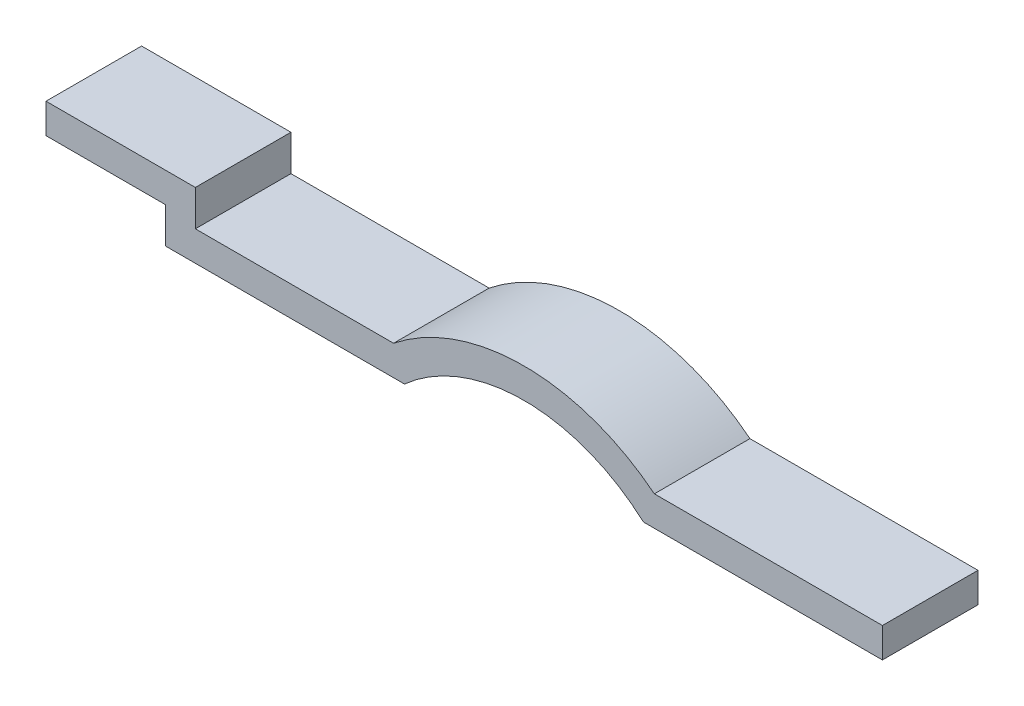
from build123d import *

# Parameters (mm, degrees)
BOSS_EXTRUDE1_DEPTH = 80


with BuildPart() as part:
    # Sketch1 → Boss-Extrude1 (new body)
    with BuildSketch(Plane.XY):
        with BuildLine():
            Line((0, 0), (-200, 0))
            ThreePointArc((-200, 0), (-300, 38.196601125), (-400, 0))
            Line((-400, 0), (-600, 0))
            Line((-600, 0), (-600, 30))
            Line((-600, 30), (-700, 30))
            Line((-700, 30), (-700, 55))
            Line((-700, 55), (-575, 55))
            Line((-575, 55), (-575, 25))
            Line((-575, 25), (-409.132167834, 25))
            ThreePointArc((-409.132167834, 25), (-300, 63.196601125), (-190.867832166, 25))
            Line((-190.867832166, 25), (0, 25))
            Line((0, 25), (0, 0))
        make_face()
    extrude(amount=BOSS_EXTRUDE1_DEPTH)


solid = part.part
